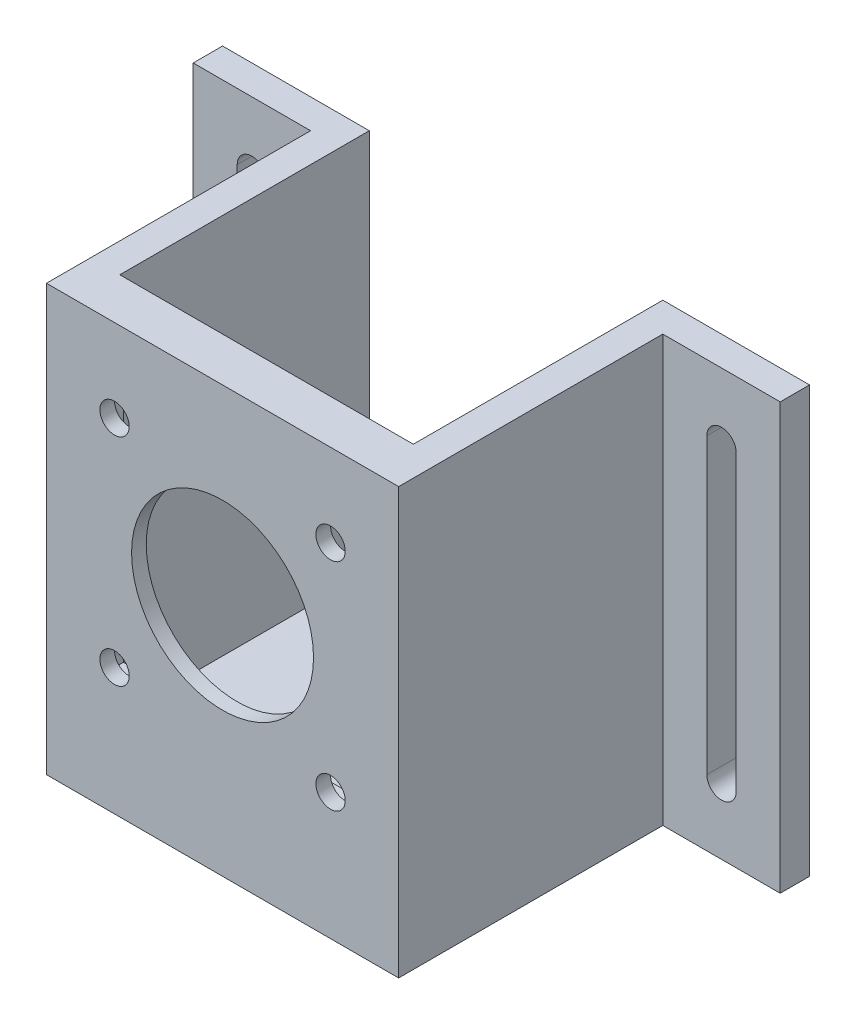
from build123d import *

# Parameters (mm, degrees)
SKETCH2_W           = 76.2
SKETCH2_H           = 63.5
BOSS_EXTRUDE1_DEPTH = 9.525
SKETCH3_W           = 76.2
SKETCH3_H           = 9.525
BOSS_EXTRUDE2_DEPTH = 82.55
SKETCH7_R           = 19.685
SKETCH7_R_2         = 3.175
CUT_EXTRUDE1_DEPTH  = 10.525
SKETCH11_W          = 61.921486798
SKETCH11_H          = 61.884587426
CUT_EXTRUDE4_DEPTH  = 6.35
SKETCH12_W          = 6.35
SKETCH12_H          = 53.975
BOSS_EXTRUDE3_DEPTH = 82.55
SKETCH14_W          = 6.35
SKETCH14_H          = 92.075
BOSS_EXTRUDE5_DEPTH = 25.4
SKETCH15_W          = 6.35
SKETCH15_H          = 92.075
BOSS_EXTRUDE6_DEPTH = 25.4
CUT_EXTRUDE5_DEPTH  = 7.35


with BuildPart() as part:
    # Sketch2 → Boss-Extrude1 (new body)
    with BuildSketch(Plane(origin=(0, 0, 0), x_dir=(1, 0, 0), z_dir=(0, 1, 0))):
        with Locations((38.1, 31.75)):
            Rectangle(SKETCH2_W, SKETCH2_H)
    extrude(amount=BOSS_EXTRUDE1_DEPTH)

    # Sketch3 → Boss-Extrude2 (add)
    with BuildSketch(Plane(origin=(0, 9.525, 0), x_dir=(1, 0, 0), z_dir=(0, 1, 0))):
        with Locations((38.1, 4.7625)):
            Rectangle(SKETCH3_W, SKETCH3_H)
    extrude(amount=BOSS_EXTRUDE2_DEPTH)

    # Sketch7 → Cut-Extrude1 (cut, through all)
    with BuildSketch(Plane(origin=(0, 0, -9.525), x_dir=(-1, 0, 0), z_dir=(0, 0, -1))):
        with Locations((-38.1, 50.8)):
            Circle(SKETCH7_R)
        with Locations((-61.468, 74.168)):
            Circle(SKETCH7_R_2)
        with Locations((-14.732, 74.168)):
            Circle(SKETCH7_R_2)
        with Locations((-14.732, 27.432)):
            Circle(SKETCH7_R_2)
        with Locations((-61.468, 27.432)):
            Circle(SKETCH7_R_2)
    extrude(amount=-CUT_EXTRUDE1_DEPTH, mode=Mode.SUBTRACT)

    # Sketch11 → Cut-Extrude4 (cut)
    with BuildSketch(Plane(origin=(0, 0, -9.525), x_dir=(-1, 0, 0), z_dir=(0, 0, -1))):
        with Locations((-38.1, 50.8)):
            Rectangle(SKETCH11_W, SKETCH11_H)
    extrude(amount=-CUT_EXTRUDE4_DEPTH, mode=Mode.SUBTRACT)

    # Sketch12 → Boss-Extrude3 (add)
    with BuildSketch(Plane(origin=(0, 9.525, 0), x_dir=(1, 0, 0), z_dir=(0, 1, 0))):
        with Locations((73.025, 36.5125)):
            Rectangle(SKETCH12_W, SKETCH12_H)
        with Locations((3.175, 36.5125)):
            Rectangle(SKETCH12_W, SKETCH12_H)
    extrude(amount=BOSS_EXTRUDE3_DEPTH)

    # Sketch14 → Boss-Extrude5 (add)
    with BuildSketch(Plane.ZY):
        with Locations((-60.325, 46.0375)):
            Rectangle(SKETCH14_W, SKETCH14_H)
    extrude(amount=BOSS_EXTRUDE5_DEPTH)

    # Sketch15 → Boss-Extrude6 (add)
    with BuildSketch(Plane(origin=(76.2, 0, 0), x_dir=(0, 0, -1), z_dir=(1, 0, 0))):
        with Locations((60.325, 46.0375)):
            Rectangle(SKETCH15_W, SKETCH15_H)
    extrude(amount=BOSS_EXTRUDE6_DEPTH)

    # Sketch16 → Cut-Extrude5 (cut, through all)
    with BuildSketch(Plane.XY.offset(-57.15)):
        with BuildLine():
            Line((-15.875, 77.7875), (-15.875, 14.2875))
            ThreePointArc((-15.875, 14.2875), (-12.7, 11.1125), (-9.525, 14.2875))
            Line((-9.525, 14.2875), (-9.525, 77.7875))
            ThreePointArc((-9.525, 77.7875), (-12.7, 80.9625), (-15.875, 77.7875))
        make_face()
        with BuildLine():
            Line((85.725, 14.2875), (85.725, 77.7875))
            ThreePointArc((85.725, 77.7875), (88.9, 80.9625), (92.075, 77.7875))
            Line((92.075, 77.7875), (92.075, 14.2875))
            ThreePointArc((92.075, 14.2875), (88.9, 11.1125), (85.725, 14.2875))
        make_face()
    extrude(amount=-CUT_EXTRUDE5_DEPTH, mode=Mode.SUBTRACT)


solid = part.part
